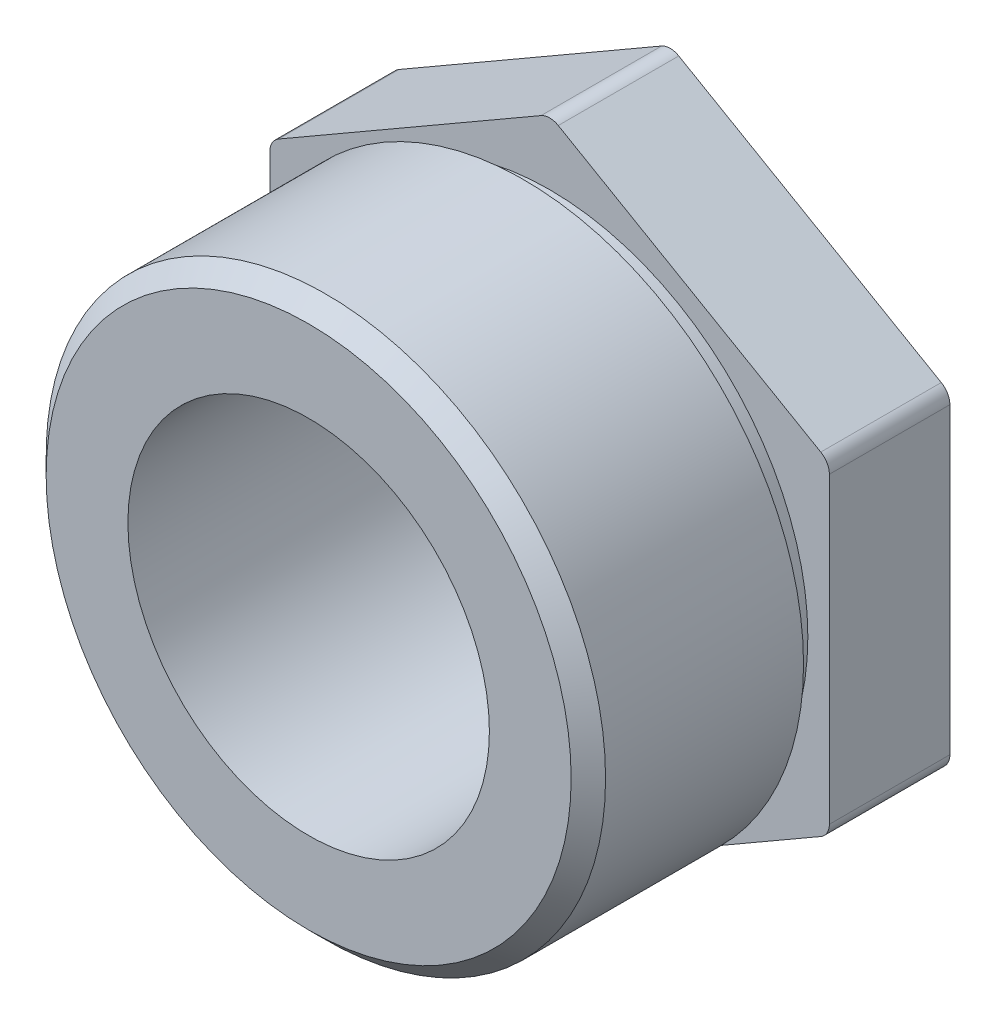
from build123d import *

# Parameters (mm, degrees)
SKETCH1_R           = 32.5
BOSS_EXTRUDE1_DEPTH = 42
CUT_EXTRUDE1_START  = -28
SKETCH2_R           = 32.5
SKETCH2_R_2         = 30
CUT_EXTRUDE1_DEPTH  = 3
BOSS_EXTRUDE2_DEPTH = 14
FILLET1_R           = 2
CHAMFER1_SIZE       = 2
SKETCH4_R           = 21
CUT_EXTRUDE2_DEPTH  = 43


with BuildPart() as part:
    # Sketch1 → Boss-Extrude1 (new body)
    with BuildSketch(Plane.XY):
        Circle(SKETCH1_R)
    extrude(amount=BOSS_EXTRUDE1_DEPTH)

    # Sketch2 → Cut-Extrude1 (cut)
    with BuildSketch(Plane.XY.offset(42).offset(CUT_EXTRUDE1_START)):
        Circle(SKETCH2_R)
        Circle(SKETCH2_R_2, mode=Mode.SUBTRACT)
    extrude(amount=CUT_EXTRUDE1_DEPTH, mode=Mode.SUBTRACT)

    # Sketch3 → Boss-Extrude2 (add)
    with BuildSketch(Plane(origin=(0, 0, 0), x_dir=(-1, 0, 0), z_dir=(0, 0, -1))):
        Polygon((0, 37.527767497), (-32.5, 18.763883749), (-32.5, -18.763883749), (0, -37.527767497), (32.5, -18.763883749), (32.5, 18.763883749), align=None)
    extrude(amount=-BOSS_EXTRUDE2_DEPTH)

    # Fillet1
    fillet1_edges = [part.edges().sort_by_distance(p)[0] for p in [
        (0, 37.527767497, 7),
        (-32.5, 18.763883749, 7),
        (-32.5, -18.763883749, 7),
        (0, -37.527767497, 7),
        (32.5, -18.763883749, 7),
        (32.5, 18.763883749, 7),
    ]]
    fillet(fillet1_edges, radius=FILLET1_R)

    # Chamfer1
    chamfer1_edges = [part.edges().sort_by_distance(p)[0] for p in [
        (-32.5, 0, 42),
    ]]
    chamfer(chamfer1_edges, length=CHAMFER1_SIZE)

    # Sketch4 → Cut-Extrude2 (cut, through all)
    with BuildSketch(Plane.XY.offset(42)):
        Circle(SKETCH4_R)
    extrude(amount=-CUT_EXTRUDE2_DEPTH, mode=Mode.SUBTRACT)


solid = part.part
